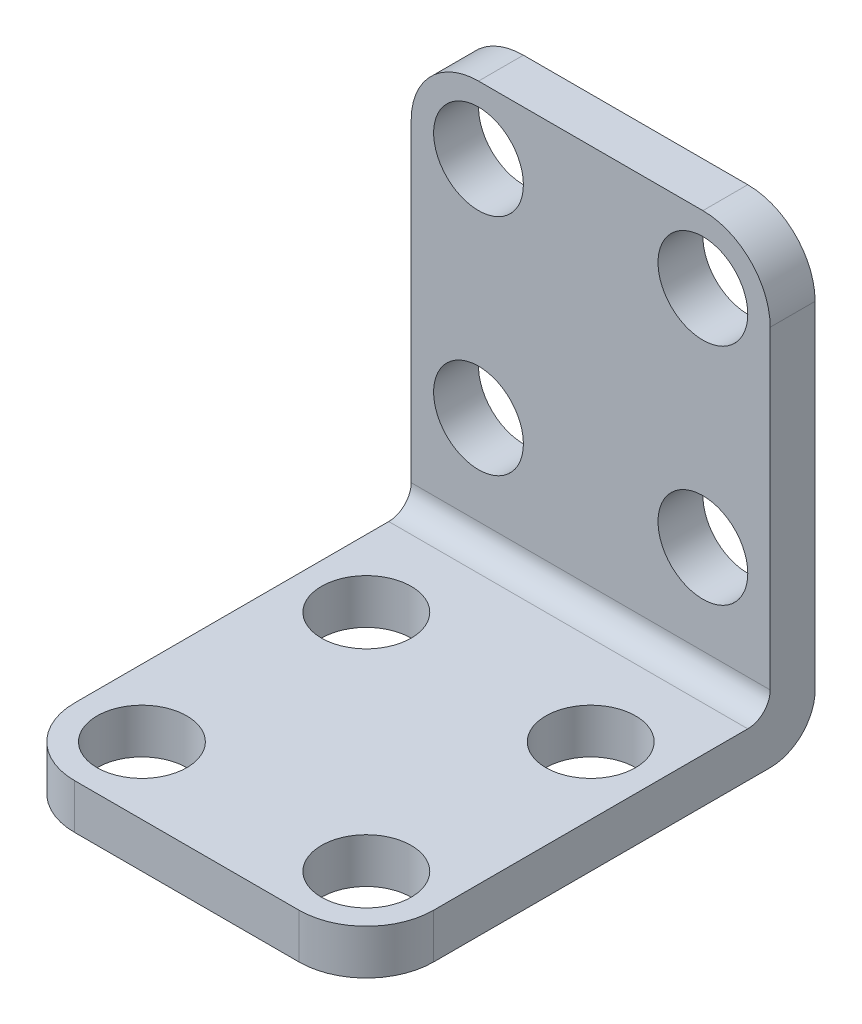
from build123d import *

# Parameters (mm, degrees)
SKETCH_6_W      = 40
SKETCH_6_H      = 50
EXTRUDE_7_DEPTH = 5
SKETCH_12_W     = 40
SKETCH_12_H     = 5
EXTRUDE_8_DEPTH = 45
FILLET_9_R      = 2.5
FILLET_10_R     = 5
MM_2_D          = 10
FILLET_11_R     = 7.5
MM_3_D          = 10


with BuildPart() as part:
    # 草图6 → 凸台-拉伸7 (new body)
    with BuildSketch(Plane.XY):
        Rectangle(SKETCH_6_W, SKETCH_6_H)
    extrude(amount=EXTRUDE_7_DEPTH)

    # 草图12 → 凸台-拉伸8 (add)
    with BuildSketch(Plane.XY.offset(5)):
        with Locations((0, -22.5)):
            Rectangle(SKETCH_12_W, SKETCH_12_H)
    extrude(amount=EXTRUDE_8_DEPTH)

    # 圆角9
    fillet_9_edges = [part.edges().sort_by_distance(p)[0] for p in [
        (0, -20, 5),
    ]]
    fillet(fillet_9_edges, radius=FILLET_9_R)

    # 圆角10
    fillet_10_edges = [part.edges().sort_by_distance(p)[0] for p in [
        (0, -25, 0),
    ]]
    fillet(fillet_10_edges, radius=FILLET_10_R)

    # 大小mm 暗销孔2 (through all)
    with Locations(Plane.XY.offset(5)):
        with Locations((-12.5, 17.5), (-12.5, -7.5), (12.5, -7.5), (12.5, 17.5)):
            Hole(MM_2_D / 2)

    # 圆角11
    fillet_11_edges = [part.edges().sort_by_distance(p)[0] for p in [
        (-20, -22.5, 50),
        (20, -22.5, 50),
        (-20, 25, 2.5),
        (20, 25, 2.5),
    ]]
    fillet(fillet_11_edges, radius=FILLET_11_R)

    # 大小mm 暗销孔3 (through all)
    with Locations(Plane(origin=(0, -20, 0), x_dir=(1, 0, 0), z_dir=(0, 1, 0))):
        with Locations((-12.5, -17.5), (12.5, -17.5), (12.5, -42.5), (-12.5, -42.5)):
            Hole(MM_3_D / 2)


solid = part.part
